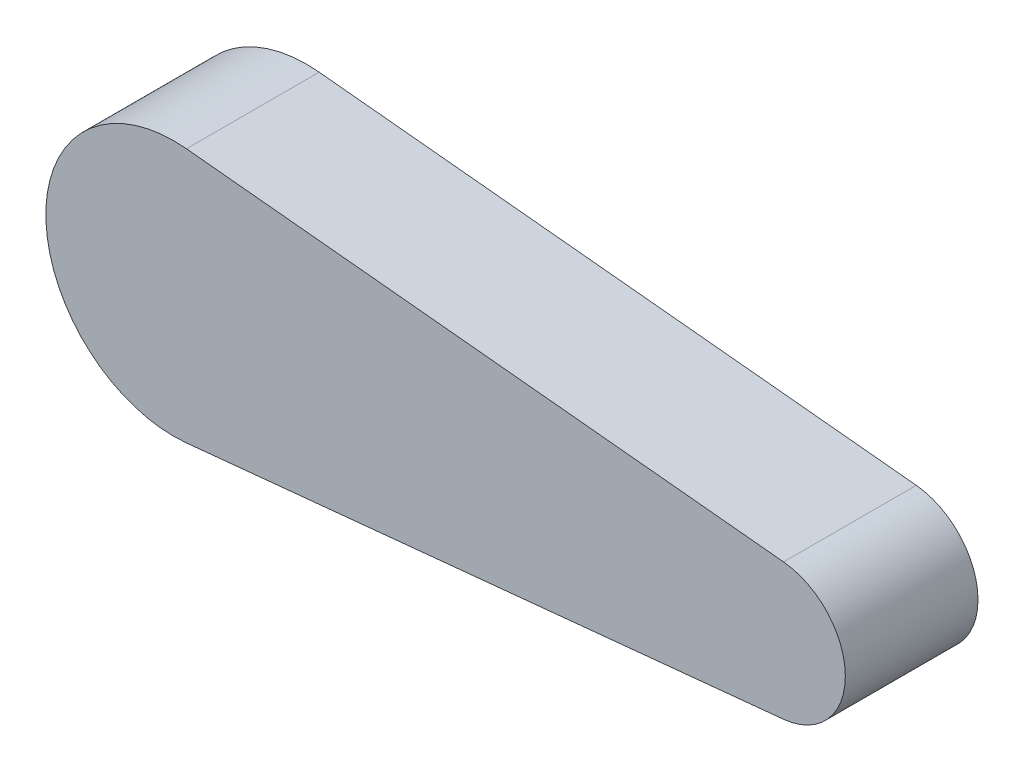
from build123d import *

# Parameters (mm, degrees)
BOSS_EXTRU_1_DEPTH = 10
SKETCH1_R          = 3.55
CUT_EXTRUDE1_DEPTH = 8


with BuildPart() as part:
    # Esquisse1 → Boss.-Extru.1 (new body)
    with BuildSketch(Plane.XY):
        with BuildLine():
            Line((10.599509188, 9.6), (55.599509188, 5.135702408))
            ThreePointArc((55.599509188, 5.135702408), (60.250926744, 0), (55.599509188, -5.135702408))
            Line((55.599509188, -5.135702408), (10.599509188, -9.6))
            ThreePointArc((10.599509188, -9.6), (0, 0), (10.599509188, 9.6))
        make_face()
    extrude(amount=BOSS_EXTRU_1_DEPTH)

    # Sketch1 → Cut-Extrude1 (cut)
    with BuildSketch(Plane(origin=(0, 0, 0), x_dir=(-1, 0, 0), z_dir=(0, 0, -1))):
        with Locations((-10.599509188, 0)):
            Circle(SKETCH1_R)
    extrude(amount=-CUT_EXTRUDE1_DEPTH, mode=Mode.SUBTRACT)


solid = part.part
